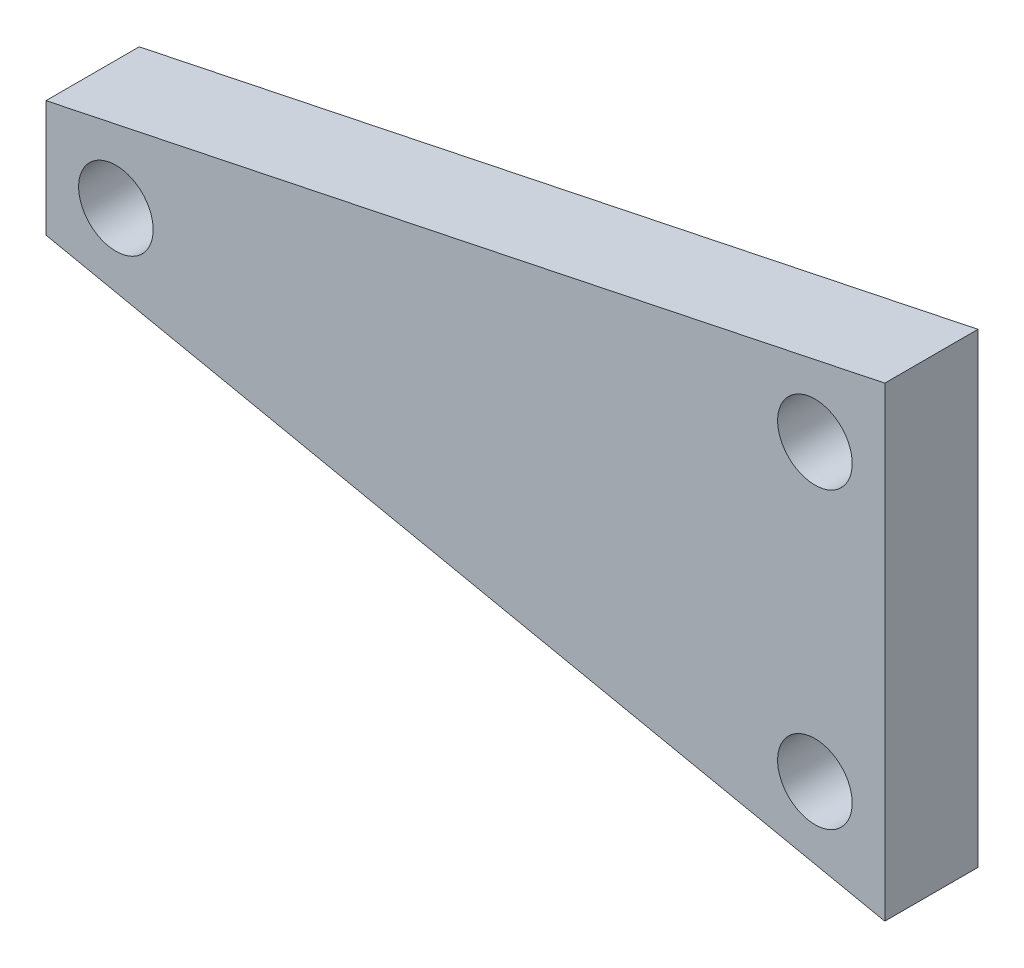
from build123d import *

# Parameters (mm, degrees)
SKETCH1_R           = 1.6
BOSS_EXTRUDE1_DEPTH = 4


with BuildPart() as part:
    # Sketch1 → Boss-Extrude1 (new body)
    with BuildSketch(Plane.XY):
        Polygon((0, 0), (0, 5), (36, 12.5), (36, -7.5), align=None)
        with Locations((3, 2.5)):
            Circle(SKETCH1_R, mode=Mode.SUBTRACT)
        with Locations((33, 8.810587332)):
            Circle(SKETCH1_R, mode=Mode.SUBTRACT)
        with Locations((33, -3.810587332)):
            Circle(SKETCH1_R, mode=Mode.SUBTRACT)
    extrude(amount=BOSS_EXTRUDE1_DEPTH)


solid = part.part
